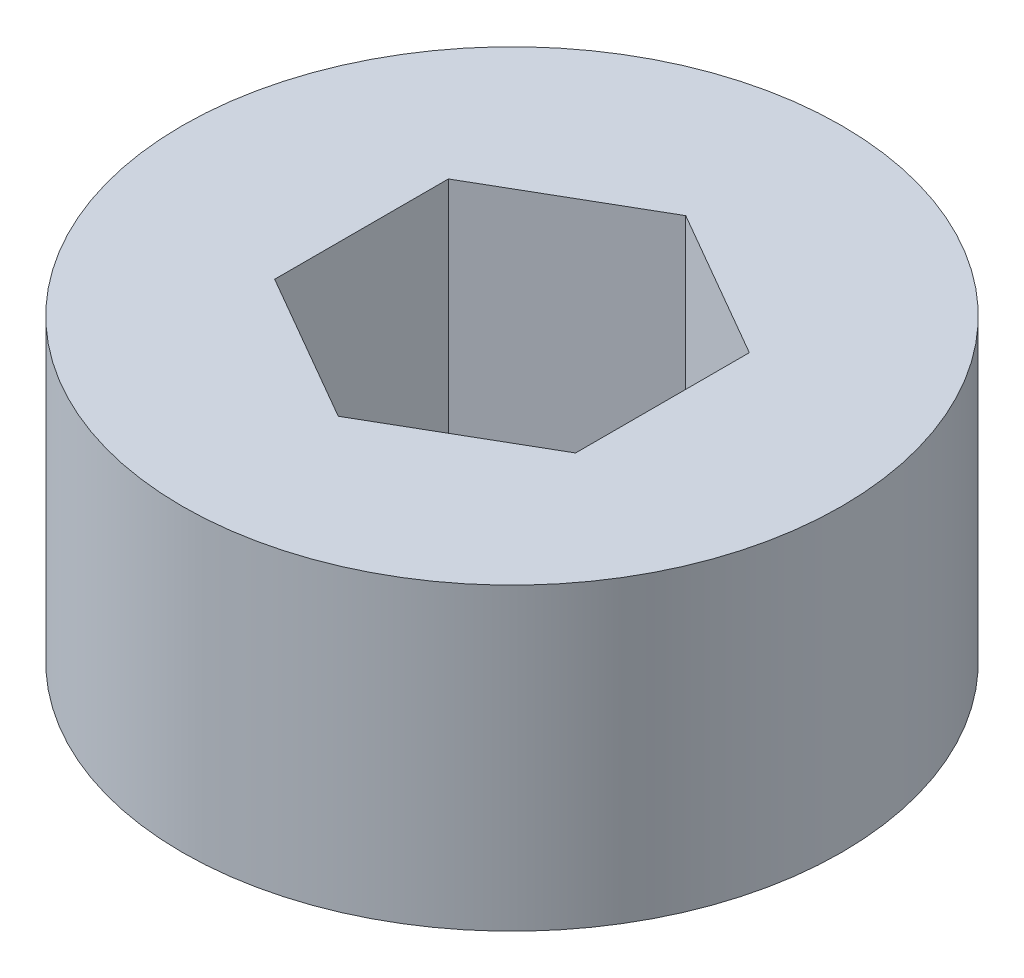
from build123d import *

# Parameters (mm, degrees)
SKETCH1_R           = 13.97
BOSS_EXTRUDE1_DEPTH = 12.7
CUT_EXTRUDE1_DEPTH  = 12.7


with BuildPart() as part:
    # Sketch1 → Boss-Extrude1 (new body)
    with BuildSketch(Plane(origin=(0, 0, 0), x_dir=(1, 0, 0), z_dir=(0, 1, 0))):
        Circle(SKETCH1_R)
    extrude(amount=BOSS_EXTRUDE1_DEPTH)

    # Sketch2 → Cut-Extrude1 (cut)
    with BuildSketch(Plane(origin=(0, 12.7, 0), x_dir=(1, 0, 0), z_dir=(0, 1, 0))):
        Polygon((0, 7.361677812), (-6.3754, 3.680838906), (-6.3754, -3.680838906), (0, -7.361677812), (6.3754, -3.680838906), (6.3754, 3.680838906), align=None)
    extrude(amount=-CUT_EXTRUDE1_DEPTH, mode=Mode.SUBTRACT)


solid = part.part
